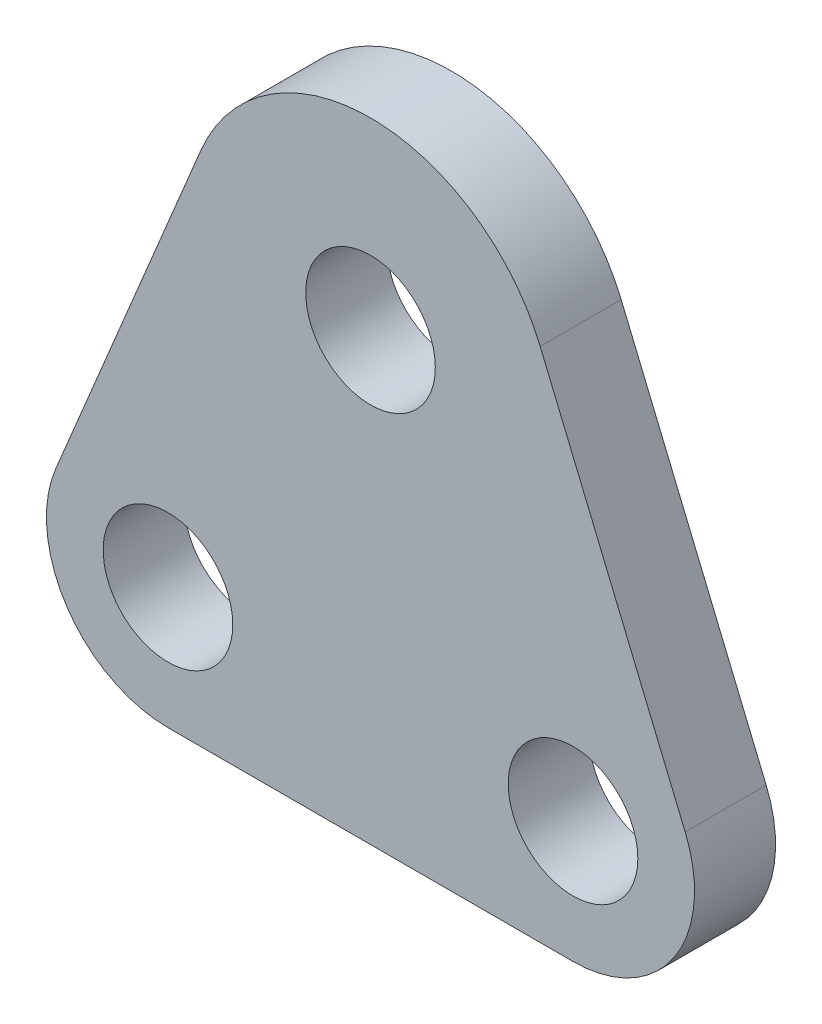
from build123d import *

# Parameters (mm, degrees)
SKETCH1_R           = 1.6
BOSS_EXTRUDE2_DEPTH = 2


with BuildPart() as part:
    # Sketch1 → Boss-Extrude2 (new body)
    with BuildSketch(Plane.XY):
        with BuildLine():
            Line((0, -3), (9.999997972, -3))
            ThreePointArc((9.999997972, -3), (12.496148784, -1.664100694), (12.769228838, 1.15384592))
            Line((12.769228838, 1.15384592), (9.189348108, 9.745561719))
            ThreePointArc((9.189348108, 9.745561719), (4.999998986, 12.538461389), (0.810649864, 9.745561719))
            Line((0.810649864, 9.745561719), (-2.769230867, 1.15384592))
            ThreePointArc((-2.769230867, 1.15384592), (-2.496150813, -1.664100694), (0, -3))
        make_face()
        with Locations((9.999997972, 0)):
            Circle(SKETCH1_R, mode=Mode.SUBTRACT)
        Circle(SKETCH1_R, mode=Mode.SUBTRACT)
        with Locations((4.999998986, 8)):
            Circle(SKETCH1_R, mode=Mode.SUBTRACT)
    extrude(amount=BOSS_EXTRUDE2_DEPTH)


solid = part.part
